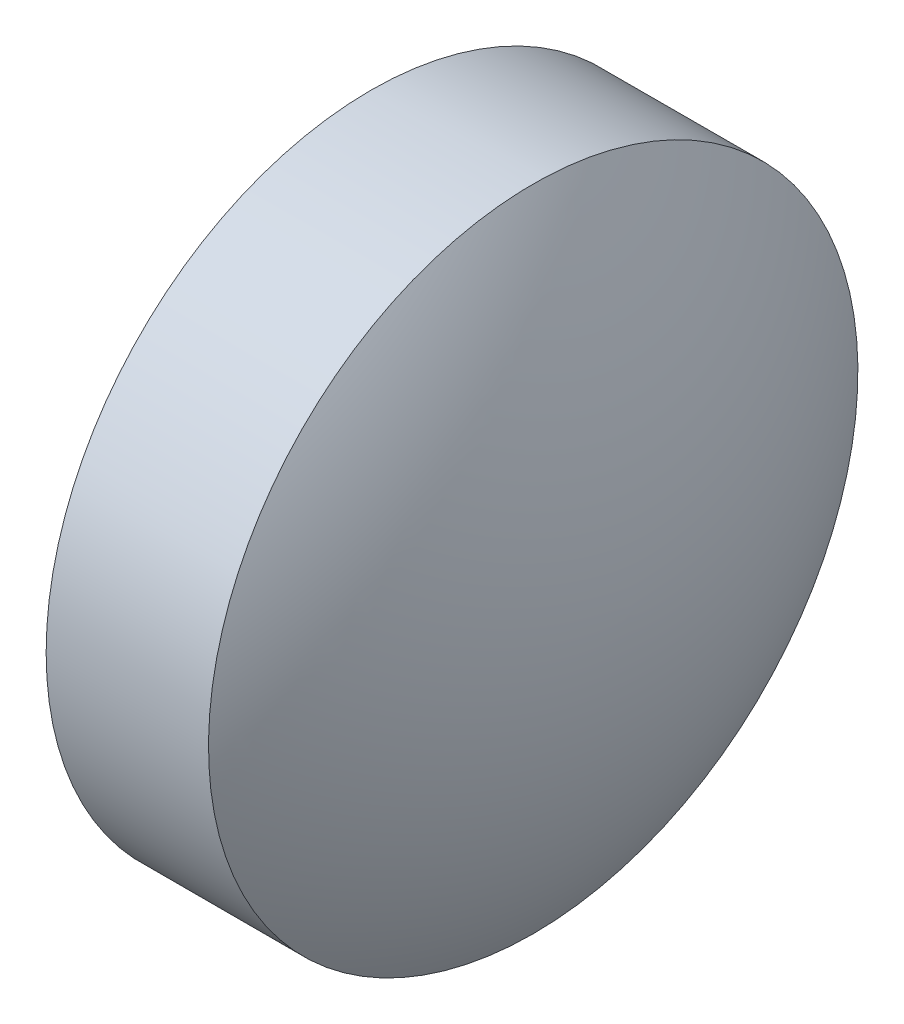
from build123d import *


with BuildPart() as part:
    # 草图2 one side → 旋转1 (revolve)
    with BuildSketch(Plane.XY):
        Polygon((10.728138038, 5.242101977), (10.711656042, 7.242101977), (9.711656042, 7.242101977), (9.711656042, 5.242101977), align=None)
        with BuildLine():
            Line((9.139926423, 5.242101977), (9.711656042, 5.242101977))
            Line((9.711656042, 5.242101977), (9.711656042, 7.242101977))
            ThreePointArc((9.711656042, 7.242101977), (9.285665343, 6.282159037), (9.139926423, 5.242101977))
        make_face()
        with BuildLine():
            Line((10.728138038, 5.242101977), (11.299926423, 5.242101977))
            ThreePointArc((11.299926423, 5.242101977), (11.146239943, 6.283412885), (10.711656042, 7.242101977))
            Line((10.711656042, 7.242101977), (10.728138038, 5.242101977))
        make_face()
    revolve(axis=Axis((9.139926423, 5.242101977, 0), (1, 0, 0)))


solid = part.part
